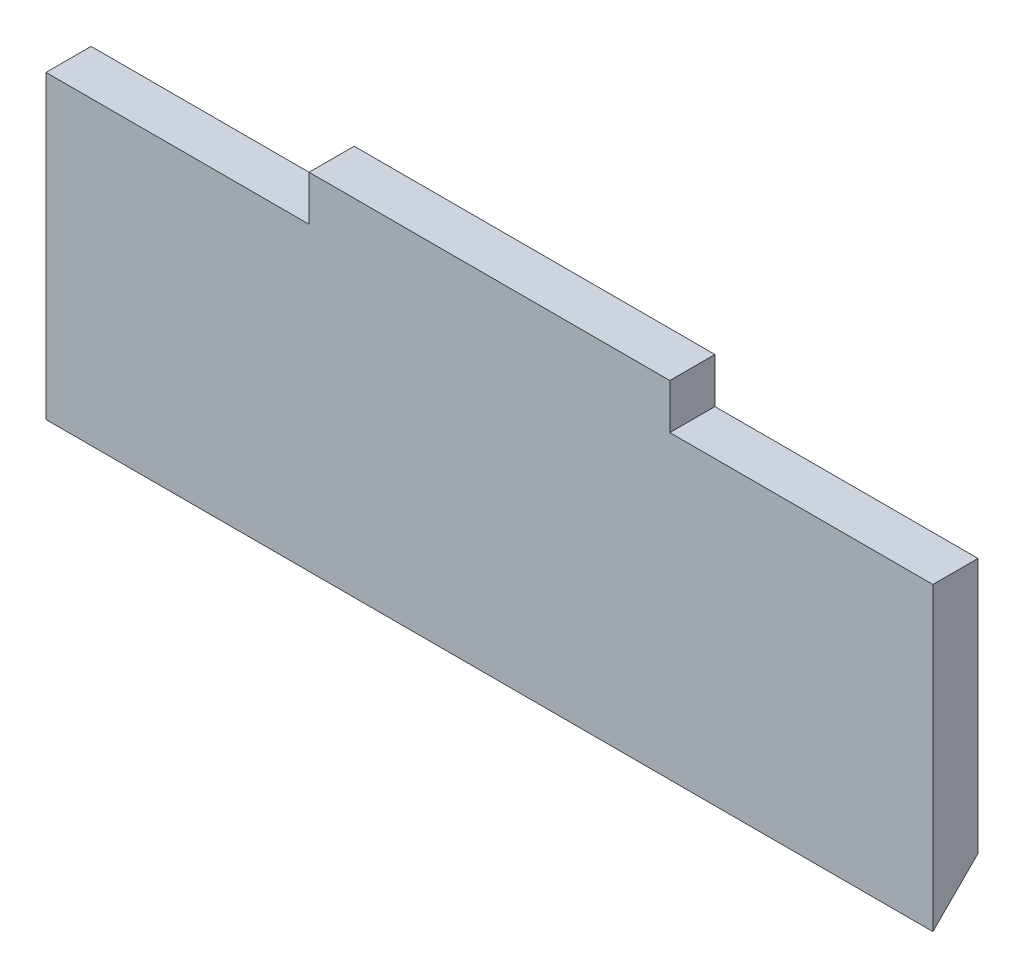
from build123d import *

# Parameters (mm, degrees)
ESQUISSE1_W        = 120
ESQUISSE1_H        = 40
BOSS_EXTRU_1_DEPTH = 6
ESQUISSE2_W        = 50
ESQUISSE2_H        = 6
BOSS_EXTRU_2_DEPTH = 6
CUT_EXTRUDE1_DEPTH = 40
CUT_EXTRUDE2_DEPTH = 40
SKETCH3_W          = 1
SKETCH3_H          = 40
SKETCH3_H_2        = 6
CUT_EXTRUDE3_DEPTH = 7


with BuildPart() as part:
    # Esquisse1 → Boss.-Extru.1 (new body)
    with BuildSketch(Plane.XY):
        Rectangle(ESQUISSE1_W, ESQUISSE1_H)
    extrude(amount=BOSS_EXTRU_1_DEPTH)

    # Esquisse2 → Boss.-Extru.2 (add)
    with BuildSketch(Plane.XY.offset(6)):
        with Locations((0, 23)):
            Rectangle(ESQUISSE2_W, ESQUISSE2_H)
    extrude(amount=-BOSS_EXTRU_2_DEPTH)

    # Sketch1 → Cut-Extrude1 (cut)
    with BuildSketch(Plane.ZY.offset(60)):
        Polygon((6, -20), (0, -14), (0, -20), align=None)
    extrude(amount=-CUT_EXTRUDE1_DEPTH, mode=Mode.SUBTRACT)

    # Sketch2 → Cut-Extrude2 (cut)
    with BuildSketch(Plane(origin=(60, 0, 0), x_dir=(0, 0, -1), z_dir=(1, 0, 0))):
        Polygon((-6, -20), (0, -14), (0, -20), align=None)
    extrude(amount=-CUT_EXTRUDE2_DEPTH, mode=Mode.SUBTRACT)

    # Sketch3 → Cut-Extrude3 (cut, through all)
    with BuildSketch(Plane.XY.offset(6)):
        with Locations((59.5, 0)):
            Rectangle(SKETCH3_W, SKETCH3_H)
        with Locations((24.5, 23)):
            Rectangle(SKETCH3_W, SKETCH3_H_2)
        with Locations((-24.5, 23)):
            Rectangle(SKETCH3_W, SKETCH3_H_2)
        with Locations((-59.5, 0)):
            Rectangle(SKETCH3_W, SKETCH3_H)
    extrude(amount=-CUT_EXTRUDE3_DEPTH, mode=Mode.SUBTRACT)


solid = part.part
